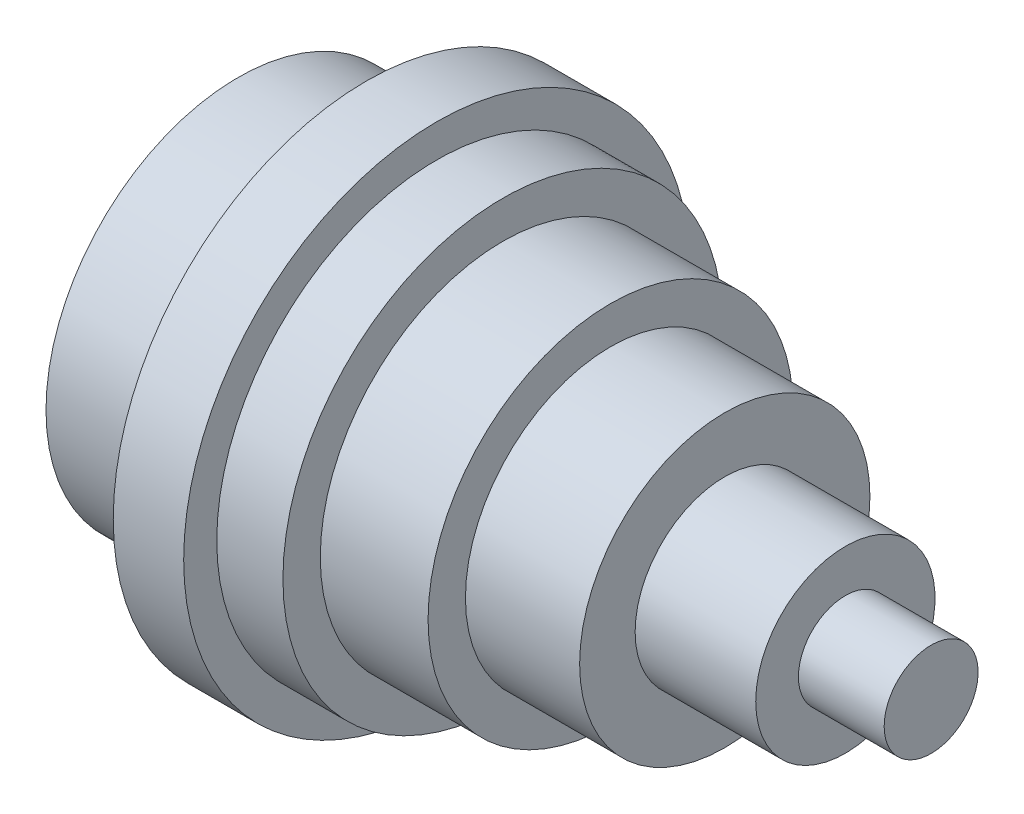
from build123d import *


with BuildPart() as part:
    # Sketch2 → Revolve1 (revolve)
    with BuildSketch(Plane.XY, mode=Mode.PRIVATE) as revolve1_sk:
        Polygon((0, 0), (0, -5), (-9.129378178, -5), (-9.129378178, -9.54507471), (-21.969214234, -9.54507471), (-21.969214234, -15.453671833), (-34.127289084, -15.453671833), (-34.127289084, -19.430612205), (-45.603602727, -19.430612205), (-45.603602727, -23.407552576), (-52.648468528, -23.407552576), (-52.648468528, -26.929985476), (-60.147841799, -26.929985476), (-60.147841799, -20.453254015), (-73.78306593, -20.453254015), (-73.78306593, 0), align=None)
    revolve(revolve1_sk.sketch.rotate(Axis((-108.212006859, 0, 0), (1, 0, 0)), 270), axis=Axis((-108.212006859, 0, 0), (1, 0, 0)))  # turned: the seam where the file's is


solid = part.part
